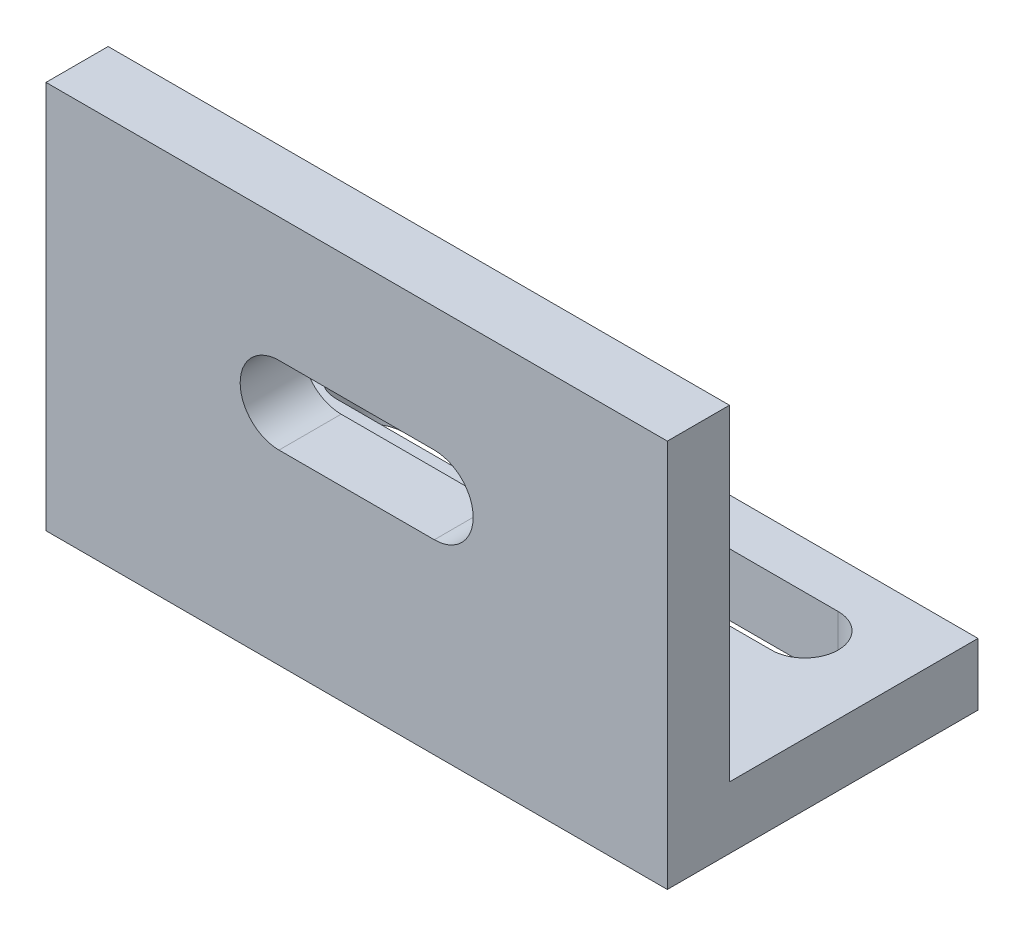
from build123d import *

# Parameters (mm, degrees)
SKETCH1_W           = 40
SKETCH1_H           = 20
BOSS_EXTRUDE1_DEPTH = 4
SKETCH5_W           = 40
SKETCH5_H           = 4
BOSS_EXTRUDE2_DEPTH = 21
CUT_EXTRUDE3_DEPTH  = 10
CUT_EXTRUDE5_DEPTH  = 10


with BuildPart() as part:
    # Sketch1 → Boss-Extrude1 (new body)
    with BuildSketch(Plane(origin=(0, 0, 0), x_dir=(1, 0, 0), z_dir=(0, 1, 0))):
        with Locations((-29.259259259, 2.888888889)):
            Rectangle(SKETCH1_W, SKETCH1_H)
    extrude(amount=BOSS_EXTRUDE1_DEPTH)

    # Sketch5 → Boss-Extrude2 (add)
    with BuildSketch(Plane(origin=(0, 4, 0), x_dir=(1, 0, 0), z_dir=(0, 1, 0))):
        with Locations((-29.259259259, -5.111111111)):
            Rectangle(SKETCH5_W, SKETCH5_H)
    extrude(amount=BOSS_EXTRUDE2_DEPTH)

    # Sketch7 → Cut-Extrude3 (cut)
    with BuildSketch(Plane(origin=(0, 4, 0), x_dir=(1, 0, 0), z_dir=(0, 1, 0))):
        with BuildLine():
            Line((-15.259259259, 5.588888889), (-43.259259259, 5.588888889))
            ThreePointArc((-43.259259259, 5.588888889), (-45.409259259, 7.738888889), (-43.259259259, 9.888888889))
            Line((-43.259259259, 9.888888889), (-15.259259259, 9.888888889))
            ThreePointArc((-15.259259259, 9.888888889), (-13.109259259, 7.738888889), (-15.259259259, 5.588888889))
        make_face()
    extrude(amount=-CUT_EXTRUDE3_DEPTH, mode=Mode.SUBTRACT)

    # Sketch8 → Cut-Extrude5 (cut)
    with BuildSketch(Plane(origin=(0, 0, 3.111111111), x_dir=(-1, 0, 0), z_dir=(0, 0, -1))):
        with BuildLine():
            Line((24.259259259, 17), (34.259259259, 17))
            ThreePointArc((34.259259259, 17), (36.759259259, 14.5), (34.259259259, 12))
            Line((34.259259259, 12), (24.259259259, 12))
            ThreePointArc((24.259259259, 12), (21.759259259, 14.5), (24.259259259, 17))
        make_face()
    extrude(amount=-CUT_EXTRUDE5_DEPTH, mode=Mode.SUBTRACT)


solid = part.part
